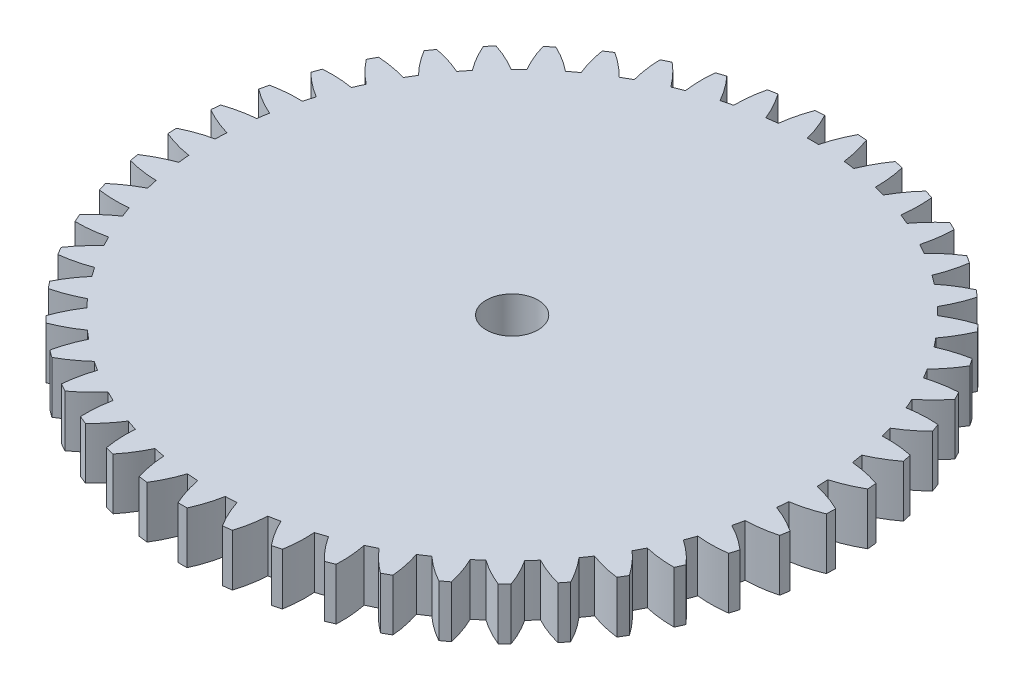
from build123d import *

# Parameters (mm, degrees)
SKETCH1_R           = 1.5875
BOSS_EXTRUDE1_DEPTH = 3.175


with BuildPart() as part:
    # Sketch1 → Boss-Extrude1 (new body)
    with BuildSketch(Plane(origin=(0, 0, 0), x_dir=(1, 0, 0), z_dir=(0, 1, 0))):
        with BuildLine():
            ThreePointArc((-2.017960001, 18.329250869), (-2.358054861, 18.288607855), (-2.69733616, 18.241655014))
            ThreePointArc((-2.69733616, 18.241655014), (-3.0933376, 19.086948402), (-3.587481444, 19.878882687))
            ThreePointArc((-3.587481444, 19.878882687), (-3.8614043, 19.827494971), (-4.134592099, 19.772332897))
            ThreePointArc((-4.134592099, 19.772332897), (-4.295435502, 18.852839856), (-4.345285154, 17.920716976))
            ThreePointArc((-4.345285154, 17.920716976), (-4.677390527, 17.836917274), (-5.007882135, 17.746963586))
            ThreePointArc((-5.007882135, 17.746963586), (-5.508726127, 18.534677587), (-6.100083367, 19.25692039))
            ThreePointArc((-6.100083367, 19.25692039), (-6.365186004, 19.17092609), (-6.629076966, 19.081282415))
            ThreePointArc((-6.629076966, 19.081282415), (-6.671017686, 18.148770201), (-6.601260845, 17.217925405))
            ThreePointArc((-6.601260845, 17.217925405), (-6.91992357, 17.092345005), (-7.236198824, 16.960867507))
            ThreePointArc((-7.236198824, 16.960867507), (-7.833661525, 17.678067878), (-8.512522089, 18.318759993))
            ThreePointArc((-8.512522089, 18.318759993), (-8.76445153, 18.199571132), (-9.014712572, 18.076917803))
            ThreePointArc((-9.014712572, 18.076917803), (-8.937061945, 17.146698242), (-8.748844016, 16.232415975))
            ThreePointArc((-8.748844016, 16.232415975), (-9.048831659, 16.067116904), (-9.345697328, 15.896274452))
            ThreePointArc((-9.345697328, 15.896274452), (-10.029968416, 16.531184784), (-10.785185434, 17.079806063))
            ThreePointArc((-10.785185434, 17.079806063), (-11.019805004, 16.929379719), (-11.252326847, 16.7757307))
            ThreePointArc((-11.252326847, 16.7757307), (-11.056359893, 15.863077971), (-10.75277141, 14.980370724))
            ThreePointArc((-10.75277141, 14.980370724), (-11.029158182, 14.778067187), (-11.30173974, 14.57066501))
            ThreePointArc((-11.30173974, 14.57066501), (-12.061583504, 15.112860093), (-12.880756332, 15.56040219))
            ThreePointArc((-12.880756332, 15.56040219), (-13.094213585, 15.381208359), (-13.305178226, 15.199086564))
            ThreePointArc((-13.305178226, 15.199086564), (-12.994112718, 14.318986398), (-12.580138594, 13.482348199))
            ThreePointArc((-12.580138594, 13.482348199), (-12.828386233, 13.246362016), (-13.072207899, 13.005805652))
            ThreePointArc((-13.072207899, 13.005805652), (-13.895147723, 13.446382656), (-14.764825567, 13.785496943))
            ThreePointArc((-14.764825567, 13.785496943), (-14.953615541, 13.580477983), (-15.139558947, 13.372873846))
            ThreePointArc((-15.139558947, 13.372873846), (-14.718502571, 12.539777465), (-14.200940251, 11.76294589))
            ThreePointArc((-14.200940251, 11.76294589), (-14.416972537, 11.497151946), (-14.628030765, 11.227391324))
            ThreePointArc((-14.628030765, 11.227391324), (-15.500554002, 11.559115989), (-16.406456775, 11.784234217))
            ThreePointArc((-16.406456775, 11.784234217), (-16.567479543, 11.556756534), (-16.725348528, 11.327078909))
            ThreePointArc((-16.725348528, 11.327078909), (-16.201215018, 10.554665732), (-15.588562861, 9.850396334))
            ThreePointArc((-15.588562861, 9.850396334), (-15.76883255, 9.55915896), (-15.94366177, 9.264623541))
            ThreePointArc((-15.94366177, 9.264623541), (-16.851441612, 9.482048956), (-17.778694416, 9.589474692))
            ThreePointArc((-17.778694416, 9.589474692), (-17.909305989, 9.343273463), (-18.036508349, 9.09529365))
            ThreePointArc((-18.036508349, 9.09529365), (-17.417903963, 8.39624668), (-16.7202217, 7.776103543))
            ThreePointArc((-16.7202217, 7.776103543), (-16.861768768, 7.464204847), (-16.99749829, 7.149730896))
            ThreePointArc((-16.99749829, 7.149730896), (-17.925629016, 7.249286941), (-18.859006386, 7.237256257))
            ThreePointArc((-18.859006386, 7.237256257), (-18.957062125, 6.976374099), (-19.051509201, 6.71416392))
            ThreePointArc((-19.051509201, 6.71416392), (-18.348591407, 6.09996149), (-17.577334961, 5.574127346))
            ThreePointArc((-17.577334961, 5.574127346), (-17.67783521, 5.246688697), (-17.772236358, 4.917439867))
            ThreePointArc((-17.772236358, 4.917439867), (-18.705478088, 4.897491836), (-19.629653993, 4.766202274))
            ThreePointArc((-19.629653993, 4.766202274), (-19.693543826, 4.494922866), (-19.753684799, 4.222787805))
            ThreePointArc((-19.753684799, 4.222787805), (-18.977995487, 3.7035151), (-18.145828868, 3.280624133))
            ThreePointArc((-18.145828868, 3.280624133), (-18.203632086, 2.943022064), (-18.255154796, 2.604404612))
            ThreePointArc((-18.255154796, 2.604404612), (-19.178183727, 2.46528005), (-20.077983224, 2.216887382))
            ThreePointArc((-20.077983224, 2.216887382), (-20.106658082, 1.939665123), (-20.131505439, 1.662073631))
            ThreePointArc((-20.131505439, 1.662073631), (-19.295781405, 1.246257095), (-18.416368766, 0.933253162))
            ThreePointArc((-18.416368766, 0.933253162), (-18.430525827, 0.59103109), (-18.438324097, 0.248605104))
            ThreePointArc((-18.438324097, 0.248605104), (-19.335984119, -0.007411567), (-20.196632525, -0.36882874))
            ThreePointArc((-20.196632525, -0.36882874), (-20.189621567, -0.647441867), (-20.178767316, -0.925931747))
            ThreePointArc((-20.178767316, -0.925931747), (-19.296731127, -1.231464417), (-18.384512399, -1.429441799))
            ThreePointArc((-18.384512399, -1.429441799), (-18.354790843, -1.770664598), (-18.318736626, -2.111276492))
            ThreePointArc((-18.318736626, -2.111276492), (-19.176288187, -2.479981485), (-19.983653679, -2.948488704))
            ThreePointArc((-19.983653679, -2.948488704), (-19.941072025, -3.22391788), (-19.894694392, -3.498733351))
            ThreePointArc((-19.894694392, -3.498733351), (-18.980829057, -3.688965318), (-18.050782846, -3.768665367))
            ThreePointArc((-18.050782846, -3.768665367), (-17.977670701, -4.103286022), (-17.898356006, -4.436490986))
            ThreePointArc((-17.898356006, -4.436490986), (-18.701718133, -4.911830177), (-19.442543792, -5.479734565))
            ThreePointArc((-19.442543792, -5.479734565), (-19.365090631, -5.74745725), (-19.283951135, -6.01408585))
            ThreePointArc((-19.283951135, -6.01408585), (-18.353262298, -6.08589351), (-17.420659938, -6.046007553))
            ThreePointArc((-17.420659938, -6.046007553), (-17.305357703, -6.368531604), (-17.184084876, -6.688858422))
            ThreePointArc((-17.184084876, -6.688858422), (-17.920066383, -7.263026752), (-18.582187873, -7.921003336))
            ThreePointArc((-18.582187873, -7.921003336), (-18.471134985, -8.176623531), (-18.356565935, -8.430687225))
            ThreePointArc((-18.356565935, -8.430687225), (-17.42433548, -8.382891498), (-16.504490275, -8.224074462))
            ThreePointArc((-16.504490275, -8.224074462), (-16.34889121, -8.529206072), (-16.187651547, -8.831394987))
            ThreePointArc((-16.187651547, -8.831394987), (-16.84416764, -9.494964629), (-17.416712943, -10.232209451))
            ThreePointArc((-17.416712943, -10.232209451), (-17.273883813, -10.47152988), (-17.127766429, -10.70885695))
            ThreePointArc((-17.127766429, -10.70885695), (-16.209301555, -10.54224264), (-15.317317339, -10.267102295))
            ThreePointArc((-15.317317339, -10.267102295), (-15.123976375, -10.549831213), (-14.925417427, -10.82892029))
            ThreePointArc((-14.925417427, -10.82892029), (-15.491688129, -11.57099545), (-15.965256068, -12.37540297))
            ThreePointArc((-15.965256068, -12.37540297), (-15.792995946, -12.594493998), (-15.617729471, -12.811187539))
            ThreePointArc((-15.617729471, -12.811187539), (-14.728111347, -12.52849045), (-13.878634475, -12.141544593))
            ThreePointArc((-13.878634475, -12.141544593), (-13.650726266, -12.397228416), (-13.418108365, -12.648635021))
            ThreePointArc((-13.418108365, -12.648635021), (-13.884835528, -13.457030845), (-14.25165013, -14.315392714))
            ThreePointArc((-14.25165013, -14.315392714), (-14.052787522, -14.510656872), (-13.851249828, -14.703158783))
            ThreePointArc((-13.851249828, -14.703158783), (-13.005085957, -14.309020792), (-12.212064817, -13.816623065))
            ThreePointArc((-12.212064817, -13.816623065), (-11.953331609, -14.041063472), (-11.690474335, -14.260659516))
            ThreePointArc((-11.690474335, -14.260659516), (-12.049994311, -15.122102165), (-12.304032491, -16.020324106))
            ThreePointArc((-12.304032491, -16.020324106), (-12.081832716, -16.188555162), (-11.857333045, -16.353704567))
            ThreePointArc((-11.857333045, -16.353704567), (-11.068517416, -15.854597409), (-10.344973392, -15.264832968))
            ThreePointArc((-10.344973392, -15.264832968), (-10.059663578, -15.454344654), (-9.77088304, -15.638524375))
            ThreePointArc((-9.77088304, -15.638524375), (-10.017292521, -16.538868986), (-10.154382978, -17.462202219))
            ThreePointArc((-10.154382978, -17.462202219), (-9.91249455, -17.600637823), (-9.668719182, -17.735722973))
            ThreePointArc((-9.668719182, -17.735722973), (-8.950204125, -17.139841975), (-8.30801779, -16.462394735))
            ThreePointArc((-8.30801779, -16.462394735), (-8.000816149, -16.613865924), (-7.690854115, -16.759605096))
            ThreePointArc((-7.690854115, -16.759605096), (-7.820107064, -17.684068036), (-7.837998778, -18.617351454))
            ThreePointArc((-7.837998778, -18.617351454), (-7.580393499, -18.723718498), (-7.321345217, -18.826521299))
            ThreePointArc((-7.321345217, -18.826521299), (-6.684928729, -18.143650809), (-6.134644765, -17.389644436))
            ThreePointArc((-6.134644765, -17.389644436), (-5.81059554, -17.500587975), (-5.484541578, -17.605493565))
            ThreePointArc((-5.484541578, -17.605493565), (-5.494515666, -18.538895177), (-5.392914854, -19.466804293))
            ThreePointArc((-5.392914854, -19.466804293), (-5.123822595, -19.539356233), (-4.853754966, -19.608188665))
            ThreePointArc((-4.853754966, -19.608188665), (-4.309886989, -18.849541399), (-3.860541043, -18.031356656))
            ThreePointArc((-3.860541043, -18.031356656), (-3.524965113, -18.099950855), (-3.188173021, -18.162300317))
            ThreePointArc((-3.188173021, -18.162300317), (-3.078704472, -19.089314172), (-2.859279418, -19.996612743))
            ThreePointArc((-2.859279418, -19.996612743), (-2.583118666, -20.034158279), (-2.306466192, -20.067890116))
            ThreePointArc((-2.306466192, -20.067890116), (-1.864077023, -19.24592304), (-1.523047344, -18.376994498))
            ThreePointArc((-1.523047344, -18.376994498), (-1.181454856, -18.402113042), (-0.83945475, -18.420882599))
            ThreePointArc((-0.83945475, -18.420882599), (-0.612341036, -19.326287156), (-0.278694692, -20.198077366))
            ThreePointArc((-0.278694692, -20.198077366), (0, -20.2), (0.278694692, -20.198077366))
            ThreePointArc((0.278694692, -20.198077366), (0.612341036, -19.326287156), (0.83945475, -18.420882599))
            ThreePointArc((0.83945475, -18.420882599), (1.181454856, -18.402113042), (1.523047344, -18.376994498))
            ThreePointArc((1.523047344, -18.376994498), (1.864077023, -19.24592304), (2.306466192, -20.067890116))
            ThreePointArc((2.306466192, -20.067890116), (2.583118666, -20.034158279), (2.859279418, -19.996612743))
            ThreePointArc((2.859279418, -19.996612743), (3.078704472, -19.089314172), (3.188173021, -18.162300317))
            ThreePointArc((3.188173021, -18.162300317), (3.524965113, -18.099950855), (3.860541043, -18.031356656))
            ThreePointArc((3.860541043, -18.031356656), (4.309886989, -18.849541399), (4.853754966, -19.608188665))
            ThreePointArc((4.853754966, -19.608188665), (5.123822595, -19.539356233), (5.392914854, -19.466804293))
            ThreePointArc((5.392914854, -19.466804293), (5.494515666, -18.538895177), (5.484541578, -17.605493565))
            ThreePointArc((5.484541578, -17.605493565), (5.81059554, -17.500587975), (6.134644765, -17.389644436))
            ThreePointArc((6.134644765, -17.389644436), (6.684928729, -18.143650809), (7.321345217, -18.826521299))
            ThreePointArc((7.321345217, -18.826521299), (7.580393499, -18.723718498), (7.837998778, -18.617351454))
            ThreePointArc((7.837998778, -18.617351454), (7.820107064, -17.684068036), (7.690854115, -16.759605096))
            ThreePointArc((7.690854115, -16.759605096), (8.000816149, -16.613865924), (8.30801779, -16.462394735))
            ThreePointArc((8.30801779, -16.462394735), (8.950204125, -17.139841975), (9.668719182, -17.735722973))
            ThreePointArc((9.668719182, -17.735722973), (9.91249455, -17.600637823), (10.154382978, -17.462202219))
            ThreePointArc((10.154382978, -17.462202219), (10.017292521, -16.538868986), (9.77088304, -15.638524375))
            ThreePointArc((9.77088304, -15.638524375), (10.059663578, -15.454344654), (10.344973392, -15.264832968))
            ThreePointArc((10.344973392, -15.264832968), (11.068517416, -15.854597409), (11.857333045, -16.353704567))
            ThreePointArc((11.857333045, -16.353704567), (12.081832716, -16.188555162), (12.304032491, -16.020324106))
            ThreePointArc((12.304032491, -16.020324106), (12.049994311, -15.122102165), (11.690474335, -14.260659516))
            ThreePointArc((11.690474335, -14.260659516), (11.953331609, -14.041063472), (12.212064817, -13.816623065))
            ThreePointArc((12.212064817, -13.816623065), (13.005085957, -14.309020792), (13.851249828, -14.703158783))
            ThreePointArc((13.851249828, -14.703158783), (14.052787522, -14.510656872), (14.25165013, -14.315392714))
            ThreePointArc((14.25165013, -14.315392714), (13.884835528, -13.457030845), (13.418108365, -12.648635021))
            ThreePointArc((13.418108365, -12.648635021), (13.650726266, -12.397228416), (13.878634475, -12.141544593))
            ThreePointArc((13.878634475, -12.141544593), (14.728111347, -12.52849045), (15.617729471, -12.811187539))
            ThreePointArc((15.617729471, -12.811187539), (15.792995946, -12.594493998), (15.965256068, -12.37540297))
            ThreePointArc((15.965256068, -12.37540297), (15.491688129, -11.57099545), (14.925417427, -10.82892029))
            ThreePointArc((14.925417427, -10.82892029), (15.123976375, -10.549831213), (15.317317339, -10.267102295))
            ThreePointArc((15.317317339, -10.267102295), (16.209301555, -10.54224264), (17.127766429, -10.70885695))
            ThreePointArc((17.127766429, -10.70885695), (17.273883813, -10.47152988), (17.416712943, -10.232209451))
            ThreePointArc((17.416712943, -10.232209451), (16.84416764, -9.494964629), (16.187651547, -8.831394987))
            ThreePointArc((16.187651547, -8.831394987), (16.34889121, -8.529206072), (16.504490275, -8.224074462))
            ThreePointArc((16.504490275, -8.224074462), (17.42433548, -8.382891498), (18.356565935, -8.430687225))
            ThreePointArc((18.356565935, -8.430687225), (18.471134985, -8.176623531), (18.582187873, -7.921003336))
            ThreePointArc((18.582187873, -7.921003336), (17.920066383, -7.263026752), (17.184084876, -6.688858422))
            ThreePointArc((17.184084876, -6.688858422), (17.305357703, -6.368531604), (17.420659938, -6.046007553))
            ThreePointArc((17.420659938, -6.046007553), (18.353262298, -6.08589351), (19.283951135, -6.01408585))
            ThreePointArc((19.283951135, -6.01408585), (19.365090631, -5.74745725), (19.442543792, -5.479734565))
            ThreePointArc((19.442543792, -5.479734565), (18.701718133, -4.911830177), (17.898356006, -4.436490986))
            ThreePointArc((17.898356006, -4.436490986), (17.977670701, -4.103286022), (18.050782846, -3.768665367))
            ThreePointArc((18.050782846, -3.768665367), (18.980829057, -3.688965318), (19.894694392, -3.498733351))
            ThreePointArc((19.894694392, -3.498733351), (19.941072025, -3.22391788), (19.983653679, -2.948488704))
            ThreePointArc((19.983653679, -2.948488704), (19.176288187, -2.479981485), (18.318736626, -2.111276492))
            ThreePointArc((18.318736626, -2.111276492), (18.354790843, -1.770664598), (18.384512399, -1.429441799))
            ThreePointArc((18.384512399, -1.429441799), (19.296731127, -1.231464417), (20.178767316, -0.925931747))
            ThreePointArc((20.178767316, -0.925931747), (20.189621567, -0.647441867), (20.196632525, -0.36882874))
            ThreePointArc((20.196632525, -0.36882874), (19.335984119, -0.007411567), (18.438324097, 0.248605104))
            ThreePointArc((18.438324097, 0.248605104), (18.430525827, 0.59103109), (18.416368766, 0.933253162))
            ThreePointArc((18.416368766, 0.933253162), (19.295781405, 1.246257095), (20.131505439, 1.662073631))
            ThreePointArc((20.131505439, 1.662073631), (20.106658082, 1.939665123), (20.077983224, 2.216887382))
            ThreePointArc((20.077983224, 2.216887382), (19.178183727, 2.46528005), (18.255154796, 2.604404612))
            ThreePointArc((18.255154796, 2.604404612), (18.203632086, 2.943022064), (18.145828868, 3.280624133))
            ThreePointArc((18.145828868, 3.280624133), (18.977995487, 3.7035151), (19.753684799, 4.222787805))
            ThreePointArc((19.753684799, 4.222787805), (19.693543826, 4.494922866), (19.629653993, 4.766202274))
            ThreePointArc((19.629653993, 4.766202274), (18.705478088, 4.897491836), (17.772236358, 4.917439867))
            ThreePointArc((17.772236358, 4.917439867), (17.67783521, 5.246688697), (17.577334961, 5.574127346))
            ThreePointArc((17.577334961, 5.574127346), (18.348591407, 6.09996149), (19.051509201, 6.71416392))
            ThreePointArc((19.051509201, 6.71416392), (18.957062125, 6.976374099), (18.859006386, 7.237256257))
            ThreePointArc((18.859006386, 7.237256257), (17.925629016, 7.249286941), (16.99749829, 7.149730896))
            ThreePointArc((16.99749829, 7.149730896), (16.861768768, 7.464204847), (16.7202217, 7.776103543))
            ThreePointArc((16.7202217, 7.776103543), (17.417903963, 8.39624668), (18.036508349, 9.09529365))
            ThreePointArc((18.036508349, 9.09529365), (17.909305989, 9.343273463), (17.778694416, 9.589474692))
            ThreePointArc((17.778694416, 9.589474692), (16.851441612, 9.482048956), (15.94366177, 9.264623541))
            ThreePointArc((15.94366177, 9.264623541), (15.76883255, 9.55915896), (15.588562861, 9.850396334))
            ThreePointArc((15.588562861, 9.850396334), (16.201215018, 10.554665732), (16.725348528, 11.327078909))
            ThreePointArc((16.725348528, 11.327078909), (16.567479543, 11.556756534), (16.406456775, 11.784234217))
            ThreePointArc((16.406456775, 11.784234217), (15.500554002, 11.559115989), (14.628030765, 11.227391324))
            ThreePointArc((14.628030765, 11.227391324), (14.416972537, 11.497151946), (14.200940251, 11.76294589))
            ThreePointArc((14.200940251, 11.76294589), (14.718502571, 12.539777465), (15.139558947, 13.372873846))
            ThreePointArc((15.139558947, 13.372873846), (14.953615541, 13.580477983), (14.764825567, 13.785496943))
            ThreePointArc((14.764825567, 13.785496943), (13.895147723, 13.446382656), (13.072207899, 13.005805652))
            ThreePointArc((13.072207899, 13.005805652), (12.828386233, 13.246362016), (12.580138594, 13.482348199))
            ThreePointArc((12.580138594, 13.482348199), (12.994112718, 14.318986398), (13.305178226, 15.199086564))
            ThreePointArc((13.305178226, 15.199086564), (13.094213585, 15.381208359), (12.880756332, 15.56040219))
            ThreePointArc((12.880756332, 15.56040219), (12.061583504, 15.112860093), (11.30173974, 14.57066501))
            ThreePointArc((11.30173974, 14.57066501), (11.029158182, 14.778067187), (10.75277141, 14.980370724))
            ThreePointArc((10.75277141, 14.980370724), (11.056359893, 15.863077971), (11.252326847, 16.7757307))
            ThreePointArc((11.252326847, 16.7757307), (11.019805004, 16.929379719), (10.785185434, 17.079806063))
            ThreePointArc((10.785185434, 17.079806063), (10.029968416, 16.531184784), (9.345697328, 15.896274452))
            ThreePointArc((9.345697328, 15.896274452), (9.048831659, 16.067116904), (8.748844016, 16.232415975))
            ThreePointArc((8.748844016, 16.232415975), (8.937061945, 17.146698242), (9.014712572, 18.076917803))
            ThreePointArc((9.014712572, 18.076917803), (8.76445153, 18.199571132), (8.512522089, 18.318759993))
            ThreePointArc((8.512522089, 18.318759993), (7.833661525, 17.678067878), (7.236198824, 16.960867507))
            ThreePointArc((7.236198824, 16.960867507), (6.91992357, 17.092345005), (6.601260845, 17.217925405))
            ThreePointArc((6.601260845, 17.217925405), (6.671017686, 18.148770201), (6.629076966, 19.081282415))
            ThreePointArc((6.629076966, 19.081282415), (6.365186004, 19.17092609), (6.100083367, 19.25692039))
            ThreePointArc((6.100083367, 19.25692039), (5.508726127, 18.534677587), (5.007882135, 17.746963586))
            ThreePointArc((5.007882135, 17.746963586), (4.677390527, 17.836917274), (4.345285154, 17.920716976))
            ThreePointArc((4.345285154, 17.920716976), (4.295435502, 18.852839856), (4.134592099, 19.772332897))
            ThreePointArc((4.134592099, 19.772332897), (3.8614043, 19.827494971), (3.587481444, 19.878882687))
            ThreePointArc((3.587481444, 19.878882687), (3.0933376, 19.086948402), (2.69733616, 18.241655014))
            ThreePointArc((2.69733616, 18.241655014), (2.358054861, 18.288607855), (2.017960001, 18.329250869))
            ThreePointArc((2.017960001, 18.329250869), (1.849322385, 19.247346402), (1.572217344, 20.138722219))
            ThreePointArc((1.572217344, 20.138722219), (1.294218444, 20.158496934), (1.015973176, 20.17443428))
            ThreePointArc((1.015973176, 20.17443428), (0.627156554, 19.325812052), (0.3425, 18.43681897))
            ThreePointArc((0.3425, 18.43681897), (0, 18.44), (-0.3425, 18.43681897))
            ThreePointArc((-0.3425, 18.43681897), (-0.627156554, 19.325812052), (-1.015973176, 20.17443428))
            ThreePointArc((-1.015973176, 20.17443428), (-1.294218444, 20.158496934), (-1.572217344, 20.138722219))
            ThreePointArc((-1.572217344, 20.138722219), (-1.849322385, 19.247346402), (-2.017960001, 18.329250869))
        make_face()
        Circle(SKETCH1_R, mode=Mode.SUBTRACT)
    extrude(amount=BOSS_EXTRUDE1_DEPTH)


solid = part.part
